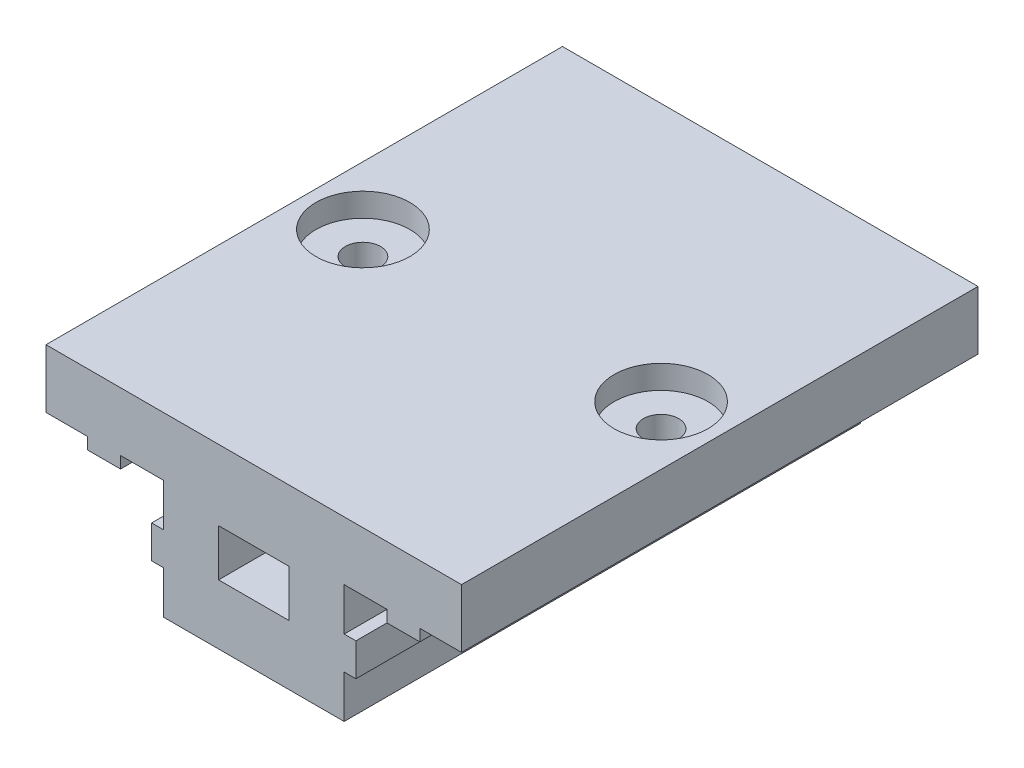
from build123d import *

# Parameters (mm, degrees)
BOSS_EXTRU_1_DEPTH      = 44
ESQUISSE3_R             = 1.5
ENL_V_MAT_EXTRU_2_DEPTH = 16.1
ESQUISSE4_R             = 4
ENL_V_MAT_EXTRU_3_DEPTH = 2
ESQUISSE5_W             = 6
ESQUISSE5_H             = 4
ENL_V_MAT_EXTRU_4_DEPTH = 45


with BuildPart() as part:
    # Esquisse1 → Boss.-Extru.1 (new body)
    with BuildSketch(Plane.XY):
        Polygon((0, 15.1), (17.7, 15.1), (17.7, 10.1), (14.15, 10.1), (14.15, 9.1), (11.35, 9.1), (11.35, 10.1), (7.7, 10.1), (7.7, 6.45), (8.7, 6.45), (8.7, 3.65), (7.7, 3.65), (7.7, 0), (0, 0), align=None)
    extrude(amount=BOSS_EXTRU_1_DEPTH)

    # Esquisse3 → Enlèv. mat.-Extru.2 (cut, through all)
    with BuildSketch(Plane(origin=(0, 15.1, 0), x_dir=(1, 0, 0), z_dir=(0, 1, 0))):
        with Locations((12.7, -22)):
            Circle(ESQUISSE3_R)
    extrude(amount=-ENL_V_MAT_EXTRU_2_DEPTH, mode=Mode.SUBTRACT)

    # Esquisse4 → Enlèv. mat.-Extru.3 (cut)
    with BuildSketch(Plane(origin=(0, 15.1, 0), x_dir=(1, 0, 0), z_dir=(0, 1, 0))):
        with Locations((12.7, -22)):
            Circle(ESQUISSE4_R)
    extrude(amount=-ENL_V_MAT_EXTRU_3_DEPTH, mode=Mode.SUBTRACT)

    # Symétrie1: part across plane


with BuildPart() as part_1:
    add(part.part)
    add(part.part.mirror(Plane(origin=(0, 0, 44), x_dir=(0, 0, 1), z_dir=(1, 0, 0))))

    # Esquisse5 → Enlèv. mat.-Extru.4 (cut, through all)
    with BuildSketch(Plane.XY.offset(44)):
        with Locations((0, 7.1)):
            Rectangle(ESQUISSE5_W, ESQUISSE5_H)
    extrude(amount=-ENL_V_MAT_EXTRU_4_DEPTH, mode=Mode.SUBTRACT)


solid = part_1.part
